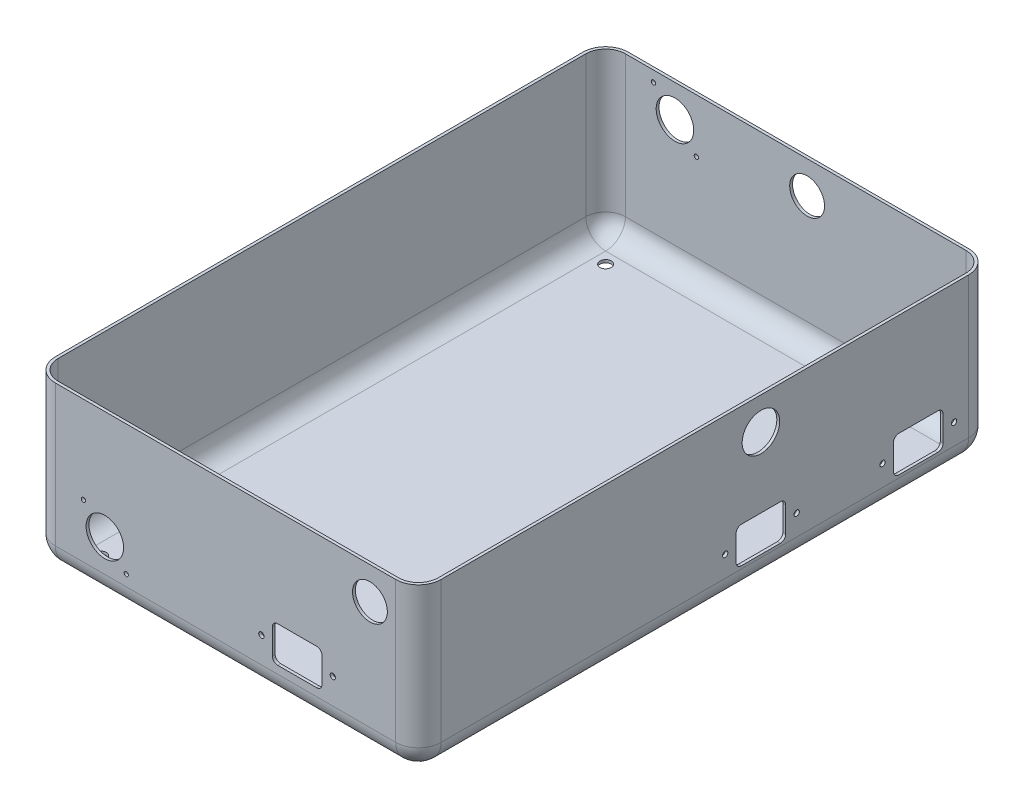
from build123d import *

# Parameters (mm, degrees)
SKETCH1_W           = 215.9
SKETCH1_H           = 320.675
BOSS_EXTRUDE1_DEPTH = 91.688940066
FILLET1_R           = 12.7
SHELL1_T            = -1.6002
CUT_EXTRUDE1_REACH  = 217.9
SKETCH2_R           = 1.5
CUT_EXTRUDE2_REACH  = 322.675
SKETCH5_R           = 1.5
SKETCH5_R_2         = 1.2
SKETCH5_R_3         = 10.5
CUT_EXTRUDE3_REACH  = 322.675
SKETCH6_R           = 1.2
SKETCH6_R_2         = 10.5
CUT_EXTRUDE4_REACH  = 93.689
SKETCH7_R           = 3.175


with BuildPart() as part:
    # Sketch1 → Boss-Extrude1 (new body)
    with BuildSketch(Plane(origin=(0, 0, 0), x_dir=(1, 0, 0), z_dir=(0, 1, 0))):
        with Locations((107.95, 160.3375)):
            Rectangle(SKETCH1_W, SKETCH1_H)
    extrude(amount=BOSS_EXTRUDE1_DEPTH)

    # Fillet1
    fillet1_edges = [part.edges().sort_by_distance(p)[0] for p in [
        (0, 0, -160.3375),
        (107.95, 0, -320.675),
        (215.9, 0, -160.3375),
        (107.95, 0, 0),
        (0, 45.844470033, 0),
        (0, 45.844470033, -320.675),
        (215.9, 45.844470033, -320.675),
        (215.9, 45.844470033, 0),
    ]]
    fillet(fillet1_edges, radius=FILLET1_R)

    # Shell1
    shell1_openings = [part.faces().sort_by_distance(p)[0] for p in [
        (107.95, 91.688940066, -160.3375),
    ]]
    offset(amount=SHELL1_T, openings=shell1_openings, kind=Kind.INTERSECTION)

    # Sketch2 → Cut-Extrude1 (cut, up to next)
    with BuildSketch(Plane(origin=(215.9, 0, 0), x_dir=(0, 0, -1), z_dir=(1, 0, 0)), mode=Mode.PRIVATE) as cut_extrude1_sk1:
        with BuildLine():
            ThreePointArc((200.8, 78.870390374), (201.843963722, 76.343158375), (202.2, 73.632070033))
            ThreePointArc((202.2, 73.632070033), (181.556036278, 70.920981691), (200.8, 78.870390374))
        make_face()
    cut_extrude1_tool1 = extrude(cut_extrude1_sk1.sketch, amount=-CUT_EXTRUDE1_REACH, mode=Mode.PRIVATE) & part.part
    add(cut_extrude1_tool1.solids().sort_by_distance((215.9, 73.63207, -191.7))[0], mode=Mode.SUBTRACT)
    # Sketch2 → Cut-Extrude1 (cut, up to next)
    with BuildSketch(Plane(origin=(215.9, 0, 0), x_dir=(0, 0, -1), z_dir=(1, 0, 0)), mode=Mode.PRIVATE) as cut_extrude1_sk2:
        with Locations((171.7, 24.3502)):
            Circle(SKETCH2_R)
    cut_extrude1_tool2 = extrude(cut_extrude1_sk2.sketch, amount=-CUT_EXTRUDE1_REACH, mode=Mode.PRIVATE) & part.part
    add(cut_extrude1_tool2.solids().sort_by_distance((215.9, 24.3502, -171.7))[0], mode=Mode.SUBTRACT)
    # Sketch2 → Cut-Extrude1 (cut, up to next)
    with BuildSketch(Plane(origin=(215.9, 0, 0), x_dir=(0, 0, -1), z_dir=(1, 0, 0)), mode=Mode.PRIVATE) as cut_extrude1_sk3:
        with Locations((211.7, 24.3502)):
            Circle(SKETCH2_R)
    cut_extrude1_tool3 = extrude(cut_extrude1_sk3.sketch, amount=-CUT_EXTRUDE1_REACH, mode=Mode.PRIVATE) & part.part
    add(cut_extrude1_tool3.solids().sort_by_distance((215.9, 24.3502, -211.7))[0], mode=Mode.SUBTRACT)
    # Sketch2 → Cut-Extrude1 (cut, up to next)
    with BuildSketch(Plane(origin=(215.9, 0, 0), x_dir=(0, 0, -1), z_dir=(1, 0, 0)), mode=Mode.PRIVATE) as cut_extrude1_sk4:
        with Locations((259.8, 24.3502)):
            Circle(SKETCH2_R)
    cut_extrude1_tool4 = extrude(cut_extrude1_sk4.sketch, amount=-CUT_EXTRUDE1_REACH, mode=Mode.PRIVATE) & part.part
    add(cut_extrude1_tool4.solids().sort_by_distance((215.9, 24.3502, -259.8))[0], mode=Mode.SUBTRACT)
    # Sketch2 → Cut-Extrude1 (cut, up to next)
    with BuildSketch(Plane(origin=(215.9, 0, 0), x_dir=(0, 0, -1), z_dir=(1, 0, 0)), mode=Mode.PRIVATE) as cut_extrude1_sk5:
        with Locations((299.8, 24.3502)):
            Circle(SKETCH2_R)
    cut_extrude1_tool5 = extrude(cut_extrude1_sk5.sketch, amount=-CUT_EXTRUDE1_REACH, mode=Mode.PRIVATE) & part.part
    add(cut_extrude1_tool5.solids().sort_by_distance((215.9, 24.3502, -299.8))[0], mode=Mode.SUBTRACT)
    # Sketch2 → Cut-Extrude1 (cut, up to next)
    with BuildSketch(Plane(origin=(215.9, 0, 0), x_dir=(0, 0, -1), z_dir=(1, 0, 0)), mode=Mode.PRIVATE) as cut_extrude1_sk6:
        with BuildLine():
            Line((268.9, 34.4002), (290.7, 34.4002))
            ThreePointArc((290.7, 34.4002), (292.821320344, 33.521520344), (293.7, 31.4002))
            Line((293.7, 31.4002), (293.7, 17.3002))
            ThreePointArc((293.7, 17.3002), (292.821320344, 15.178879656), (290.7, 14.3002))
            Line((290.7, 14.3002), (268.9, 14.3002))
            ThreePointArc((268.9, 14.3002), (266.778679656, 15.178879656), (265.9, 17.3002))
            Line((265.9, 17.3002), (265.9, 31.4002))
            ThreePointArc((265.9, 31.4002), (266.778679656, 33.521520344), (268.9, 34.4002))
        make_face()
    cut_extrude1_tool6 = extrude(cut_extrude1_sk6.sketch, amount=-CUT_EXTRUDE1_REACH, mode=Mode.PRIVATE) & part.part
    add(cut_extrude1_tool6.solids().sort_by_distance((215.9, 24.3502, -279.8))[0], mode=Mode.SUBTRACT)
    # Sketch2 → Cut-Extrude1 (cut, up to next)
    with BuildSketch(Plane(origin=(215.9, 0, 0), x_dir=(0, 0, -1), z_dir=(1, 0, 0)), mode=Mode.PRIVATE) as cut_extrude1_sk7:
        with BuildLine():
            Line((180.8, 34.4002), (202.6, 34.4002))
            ThreePointArc((202.6, 34.4002), (204.721320344, 33.521520344), (205.6, 31.4002))
            Line((205.6, 31.4002), (205.6, 17.3002))
            ThreePointArc((205.6, 17.3002), (204.721320344, 15.178879656), (202.6, 14.3002))
            Line((202.6, 14.3002), (180.8, 14.3002))
            ThreePointArc((180.8, 14.3002), (178.678679656, 15.178879656), (177.8, 17.3002))
            Line((177.8, 17.3002), (177.8, 31.4002))
            ThreePointArc((177.8, 31.4002), (178.678679656, 33.521520344), (180.8, 34.4002))
        make_face()
    cut_extrude1_tool7 = extrude(cut_extrude1_sk7.sketch, amount=-CUT_EXTRUDE1_REACH, mode=Mode.PRIVATE) & part.part
    add(cut_extrude1_tool7.solids().sort_by_distance((215.9, 24.3502, -191.7))[0], mode=Mode.SUBTRACT)

    # Sketch5 → Cut-Extrude2 (cut, up to next)
    with BuildSketch(Plane(origin=(317.5, 0, 0), x_dir=(1, 0, 0), z_dir=(0, 0, 1)), mode=Mode.PRIVATE) as cut_extrude2_sk1:
        with Locations((-189.475, 27.125)):
            Circle(SKETCH5_R)
    cut_extrude2_tool1 = extrude(cut_extrude2_sk1.sketch, amount=-CUT_EXTRUDE2_REACH, mode=Mode.PRIVATE) & part.part
    add(cut_extrude2_tool1.solids().sort_by_distance((128.025, 27.125, 0))[0], mode=Mode.SUBTRACT)
    # Sketch5 → Cut-Extrude2 (cut, up to next)
    with BuildSketch(Plane(origin=(317.5, 0, 0), x_dir=(1, 0, 0), z_dir=(0, 0, 1)), mode=Mode.PRIVATE) as cut_extrude2_sk2:
        with Locations((-149.475, 27.125)):
            Circle(SKETCH5_R)
    cut_extrude2_tool2 = extrude(cut_extrude2_sk2.sketch, amount=-CUT_EXTRUDE2_REACH, mode=Mode.PRIVATE) & part.part
    add(cut_extrude2_tool2.solids().sort_by_distance((168.025, 27.125, 0))[0], mode=Mode.SUBTRACT)
    # Sketch5 → Cut-Extrude2 (cut, up to next)
    with BuildSketch(Plane(origin=(317.5, 0, 0), x_dir=(1, 0, 0), z_dir=(0, 0, 1)), mode=Mode.PRIVATE) as cut_extrude2_sk3:
        with Locations((-289.1, 42.875)):
            Circle(SKETCH5_R_2)
    cut_extrude2_tool3 = extrude(cut_extrude2_sk3.sketch, amount=-CUT_EXTRUDE2_REACH, mode=Mode.PRIVATE) & part.part
    add(cut_extrude2_tool3.solids().sort_by_distance((28.4, 42.875, 0))[0], mode=Mode.SUBTRACT)
    # Sketch5 → Cut-Extrude2 (cut, up to next)
    with BuildSketch(Plane(origin=(317.5, 0, 0), x_dir=(1, 0, 0), z_dir=(0, 0, 1)), mode=Mode.PRIVATE) as cut_extrude2_sk4:
        with Locations((-265.1, 18.875)):
            Circle(SKETCH5_R_2)
    cut_extrude2_tool4 = extrude(cut_extrude2_sk4.sketch, amount=-CUT_EXTRUDE2_REACH, mode=Mode.PRIVATE) & part.part
    add(cut_extrude2_tool4.solids().sort_by_distance((52.4, 18.875, 0))[0], mode=Mode.SUBTRACT)
    # Sketch5 → Cut-Extrude2 (cut, up to next)
    with BuildSketch(Plane(origin=(317.5, 0, 0), x_dir=(1, 0, 0), z_dir=(0, 0, 1)), mode=Mode.PRIVATE) as cut_extrude2_sk5:
        with Locations((-277.1, 30.875)):
            Circle(SKETCH5_R_3)
    cut_extrude2_tool5 = extrude(cut_extrude2_sk5.sketch, amount=-CUT_EXTRUDE2_REACH, mode=Mode.PRIVATE) & part.part
    add(cut_extrude2_tool5.solids().sort_by_distance((40.4, 30.875, 0))[0], mode=Mode.SUBTRACT)
    # Sketch5 → Cut-Extrude2 (cut, up to next)
    with BuildSketch(Plane(origin=(317.5, 0, 0), x_dir=(1, 0, 0), z_dir=(0, 0, 1)), mode=Mode.PRIVATE) as cut_extrude2_sk6:
        with BuildLine():
            Line((-180.375, 37.175), (-158.575, 37.175))
            ThreePointArc((-158.575, 37.175), (-156.453679656, 36.296320344), (-155.575, 34.175))
            Line((-155.575, 34.175), (-155.575, 20.075))
            ThreePointArc((-155.575, 20.075), (-156.453679656, 17.953679656), (-158.575, 17.075))
            Line((-158.575, 17.075), (-180.375, 17.075))
            ThreePointArc((-180.375, 17.075), (-182.496320344, 17.953679656), (-183.375, 20.075))
            Line((-183.375, 20.075), (-183.375, 34.175))
            ThreePointArc((-183.375, 34.175), (-182.496320344, 36.296320344), (-180.375, 37.175))
        make_face()
    cut_extrude2_tool6 = extrude(cut_extrude2_sk6.sketch, amount=-CUT_EXTRUDE2_REACH, mode=Mode.PRIVATE) & part.part
    add(cut_extrude2_tool6.solids().sort_by_distance((148.025, 27.125, 0))[0], mode=Mode.SUBTRACT)
    # Sketch5 → Cut-Extrude2 (cut, up to next)
    with BuildSketch(Plane(origin=(317.5, 0, 0), x_dir=(1, 0, 0), z_dir=(0, 0, 1)), mode=Mode.PRIVATE) as cut_extrude2_sk7:
        with BuildLine():
            ThreePointArc((-123.85, 65.188322344), (-120.281252313, 78.507070031), (-133.6, 82.075817718))
            ThreePointArc((-133.6, 82.075817718), (-137.168747687, 68.757070031), (-123.85, 65.188322344))
        make_face()
    cut_extrude2_tool7 = extrude(cut_extrude2_sk7.sketch, amount=-CUT_EXTRUDE2_REACH, mode=Mode.PRIVATE) & part.part
    add(cut_extrude2_tool7.solids().sort_by_distance((188.775, 73.63207, 0))[0], mode=Mode.SUBTRACT)

    # Sketch6 → Cut-Extrude3 (cut, up to next)
    with BuildSketch(Plane(origin=(0, 0, -320.675), x_dir=(-1, 0, 0), z_dir=(0, 0, -1)), mode=Mode.PRIVATE) as cut_extrude3_sk1:
        with Locations((-28.4, 85.632070033)):
            Circle(SKETCH6_R)
    cut_extrude3_tool1 = extrude(cut_extrude3_sk1.sketch, amount=-CUT_EXTRUDE3_REACH, mode=Mode.PRIVATE) & part.part
    add(cut_extrude3_tool1.solids().sort_by_distance((28.4, 85.63207, -320.675))[0], mode=Mode.SUBTRACT)
    # Sketch6 → Cut-Extrude3 (cut, up to next)
    with BuildSketch(Plane(origin=(0, 0, -320.675), x_dir=(-1, 0, 0), z_dir=(0, 0, -1)), mode=Mode.PRIVATE) as cut_extrude3_sk2:
        with Locations((-52.4, 61.632070033)):
            Circle(SKETCH6_R)
    cut_extrude3_tool2 = extrude(cut_extrude3_sk2.sketch, amount=-CUT_EXTRUDE3_REACH, mode=Mode.PRIVATE) & part.part
    add(cut_extrude3_tool2.solids().sort_by_distance((52.4, 61.63207, -320.675))[0], mode=Mode.SUBTRACT)
    # Sketch6 → Cut-Extrude3 (cut, up to next)
    with BuildSketch(Plane(origin=(0, 0, -320.675), x_dir=(-1, 0, 0), z_dir=(0, 0, -1)), mode=Mode.PRIVATE) as cut_extrude3_sk3:
        with Locations((-40.4, 73.632070033)):
            Circle(SKETCH6_R_2)
    cut_extrude3_tool3 = extrude(cut_extrude3_sk3.sketch, amount=-CUT_EXTRUDE3_REACH, mode=Mode.PRIVATE) & part.part
    add(cut_extrude3_tool3.solids().sort_by_distance((40.4, 73.63207, -320.675))[0], mode=Mode.SUBTRACT)
    # Sketch6 → Cut-Extrude3 (cut, up to next)
    with BuildSketch(Plane(origin=(0, 0, -320.675), x_dir=(-1, 0, 0), z_dir=(0, 0, -1)), mode=Mode.PRIVATE) as cut_extrude3_sk4:
        with BuildLine():
            ThreePointArc((-109.5052, 65.188322346), (-105.936452313, 78.507070033), (-119.2552, 82.07581772))
            ThreePointArc((-119.2552, 82.07581772), (-122.823947687, 68.757070033), (-109.5052, 65.188322346))
        make_face()
    cut_extrude3_tool4 = extrude(cut_extrude3_sk4.sketch, amount=-CUT_EXTRUDE3_REACH, mode=Mode.PRIVATE) & part.part
    add(cut_extrude3_tool4.solids().sort_by_distance((114.3802, 73.63207, -320.675))[0], mode=Mode.SUBTRACT)

    # Sketch7 → Cut-Extrude4 (cut, up to next)
    with BuildSketch(Plane.XZ, mode=Mode.PRIVATE) as cut_extrude4_sk1:
        with Locations((19.05, -301.625)):
            Circle(SKETCH7_R)
    cut_extrude4_tool1 = extrude(cut_extrude4_sk1.sketch, amount=-CUT_EXTRUDE4_REACH, mode=Mode.PRIVATE) & part.part
    add(cut_extrude4_tool1.solids().sort_by_distance((19.05, 0, -301.625))[0], mode=Mode.SUBTRACT)
    # Sketch7 → Cut-Extrude4 (cut, up to next)
    with BuildSketch(Plane.XZ, mode=Mode.PRIVATE) as cut_extrude4_sk2:
        with Locations((19.05, -19.05)):
            Circle(SKETCH7_R)
    cut_extrude4_tool2 = extrude(cut_extrude4_sk2.sketch, amount=-CUT_EXTRUDE4_REACH, mode=Mode.PRIVATE) & part.part
    add(cut_extrude4_tool2.solids().sort_by_distance((19.05, 0, -19.05))[0], mode=Mode.SUBTRACT)
    # Sketch7 → Cut-Extrude4 (cut, up to next)
    with BuildSketch(Plane.XZ, mode=Mode.PRIVATE) as cut_extrude4_sk3:
        with Locations((139.7, -100.34)):
            Circle(SKETCH7_R)
    cut_extrude4_tool3 = extrude(cut_extrude4_sk3.sketch, amount=-CUT_EXTRUDE4_REACH, mode=Mode.PRIVATE) & part.part
    add(cut_extrude4_tool3.solids().sort_by_distance((139.7, 0, -100.34))[0], mode=Mode.SUBTRACT)
    # Sketch7 → Cut-Extrude4 (cut, up to next)
    with BuildSketch(Plane.XZ, mode=Mode.PRIVATE) as cut_extrude4_sk4:
        with Locations((165.1, -100.34)):
            Circle(SKETCH7_R)
    cut_extrude4_tool4 = extrude(cut_extrude4_sk4.sketch, amount=-CUT_EXTRUDE4_REACH, mode=Mode.PRIVATE) & part.part
    add(cut_extrude4_tool4.solids().sort_by_distance((165.1, 0, -100.34))[0], mode=Mode.SUBTRACT)
    # Sketch7 → Cut-Extrude4 (cut, up to next)
    with BuildSketch(Plane.XZ, mode=Mode.PRIVATE) as cut_extrude4_sk5:
        with Locations((139.7, -220.335)):
            Circle(SKETCH7_R)
    cut_extrude4_tool5 = extrude(cut_extrude4_sk5.sketch, amount=-CUT_EXTRUDE4_REACH, mode=Mode.PRIVATE) & part.part
    add(cut_extrude4_tool5.solids().sort_by_distance((139.7, 0, -220.335))[0], mode=Mode.SUBTRACT)
    # Sketch7 → Cut-Extrude4 (cut, up to next)
    with BuildSketch(Plane.XZ, mode=Mode.PRIVATE) as cut_extrude4_sk6:
        with Locations((168.275, -301.625)):
            Circle(SKETCH7_R)
    cut_extrude4_tool6 = extrude(cut_extrude4_sk6.sketch, amount=-CUT_EXTRUDE4_REACH, mode=Mode.PRIVATE) & part.part
    add(cut_extrude4_tool6.solids().sort_by_distance((168.275, 0, -301.625))[0], mode=Mode.SUBTRACT)
    # Sketch7 → Cut-Extrude4 (cut, up to next)
    with BuildSketch(Plane.XZ, mode=Mode.PRIVATE) as cut_extrude4_sk7:
        with Locations((168.275, -19.05)):
            Circle(SKETCH7_R)
    cut_extrude4_tool7 = extrude(cut_extrude4_sk7.sketch, amount=-CUT_EXTRUDE4_REACH, mode=Mode.PRIVATE) & part.part
    add(cut_extrude4_tool7.solids().sort_by_distance((168.275, 0, -19.05))[0], mode=Mode.SUBTRACT)
    # Sketch7 → Cut-Extrude4 (cut, up to next)
    with BuildSketch(Plane.XZ, mode=Mode.PRIVATE) as cut_extrude4_sk8:
        with Locations((165.1, -220.335)):
            Circle(SKETCH7_R)
    cut_extrude4_tool8 = extrude(cut_extrude4_sk8.sketch, amount=-CUT_EXTRUDE4_REACH, mode=Mode.PRIVATE) & part.part
    add(cut_extrude4_tool8.solids().sort_by_distance((165.1, 0, -220.335))[0], mode=Mode.SUBTRACT)


solid = part.part
